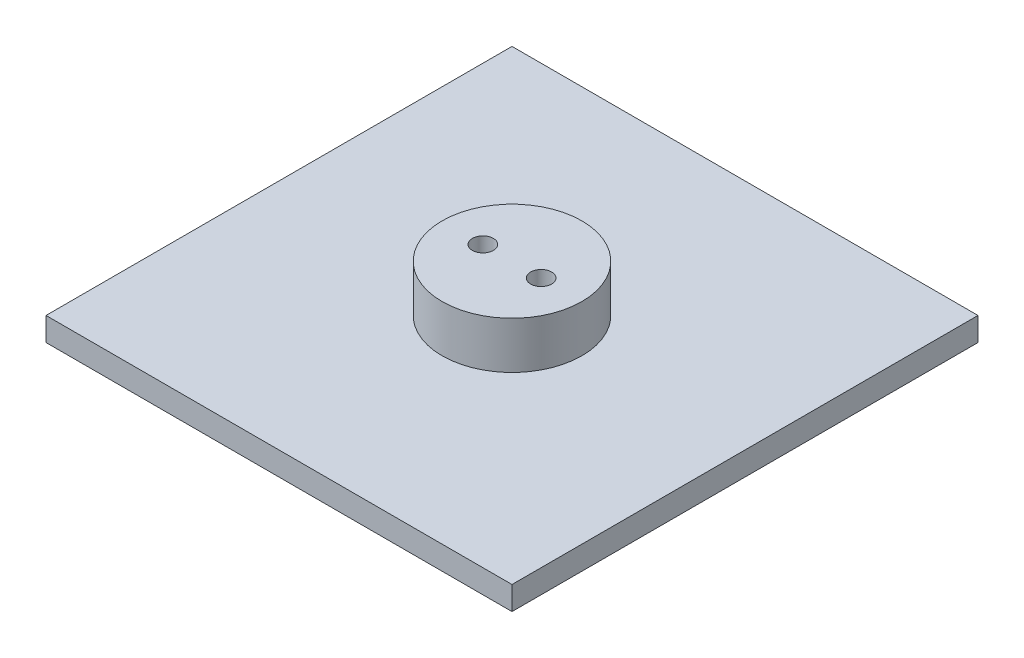
from build123d import *

# Parameters (mm, degrees)
SKETCH1_W           = 79.375
SKETCH1_H           = 79.375
BOSS_EXTRUDE1_DEPTH = 4
SKETCH2_R           = 11.90625
BOSS_EXTRUDE2_DEPTH = 8
SKETCH3_R           = 1.7859375
CUT_EXTRUDE1_DEPTH  = 12


with BuildPart() as part:
    # Sketch1 → Boss-Extrude1 (new body)
    with BuildSketch(Plane(origin=(0, 0, 0), x_dir=(1, 0, 0), z_dir=(0, 1, 0))):
        with Locations((39.6875, 39.6875)):
            Rectangle(SKETCH1_W, SKETCH1_H)
    extrude(amount=BOSS_EXTRUDE1_DEPTH)

    # Sketch2 → Boss-Extrude2 (add)
    with BuildSketch(Plane(origin=(0, 4, 0), x_dir=(1, 0, 0), z_dir=(0, 1, 0))):
        with Locations((39.6875, 39.6875)):
            Circle(SKETCH2_R)
    extrude(amount=BOSS_EXTRUDE2_DEPTH)

    # Sketch3 → Cut-Extrude1 (cut)
    with BuildSketch(Plane(origin=(0, 12, 0), x_dir=(1, 0, 0), z_dir=(0, 1, 0))):
        with Locations((34.7265625, 39.6875)):
            Circle(SKETCH3_R)
        with Locations((44.6484375, 39.6875)):
            Circle(SKETCH3_R)
    extrude(amount=-CUT_EXTRUDE1_DEPTH, mode=Mode.SUBTRACT)


solid = part.part
